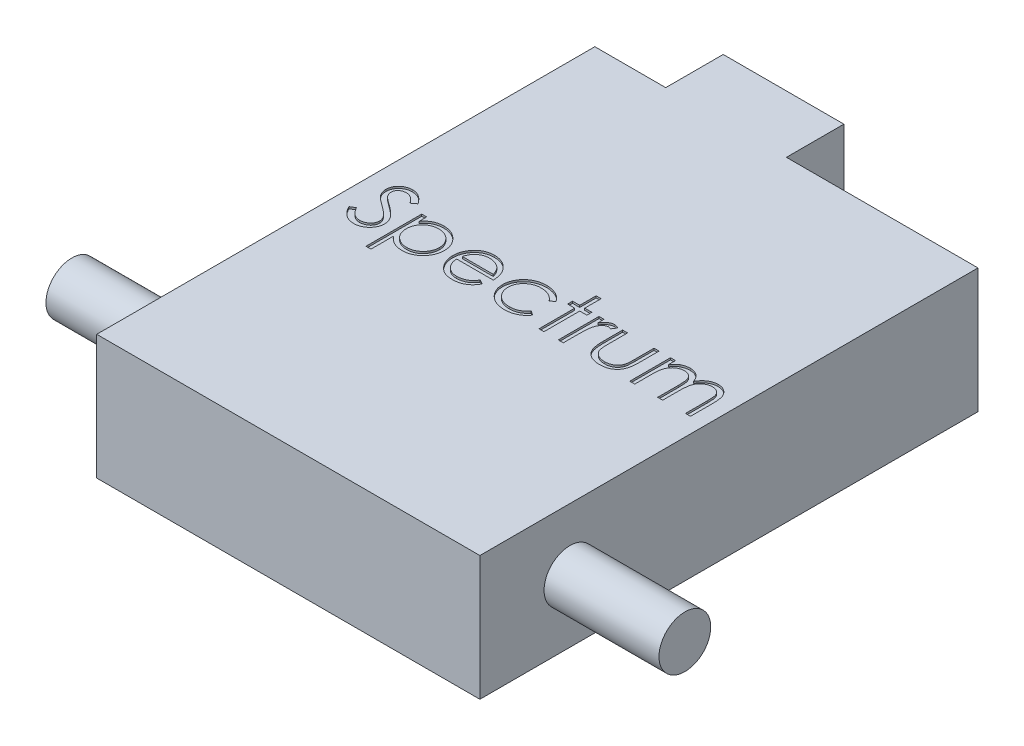
from build123d import *

# Parameters (mm, degrees)
SKETCH1_W           = 20
SKETCH1_H           = 26
BOSS_EXTRUDE1_DEPTH = 6.5
SKETCH2_R           = 1.35
BOSS_EXTRUDE2_DEPTH = 6
SKETCH3_W           = 6.3
SKETCH3_H           = 3.2
BOSS_EXTRUDE3_DEPTH = 3
CUT_EXTRUDE1_DEPTH  = 0.1


with BuildPart() as part:
    # Sketch1 → Boss-Extrude1 (new body)
    with BuildSketch(Plane(origin=(0, 0, 0), x_dir=(1, 0, 0), z_dir=(0, 1, 0))):
        Rectangle(SKETCH1_W, SKETCH1_H)
    extrude(amount=BOSS_EXTRUDE1_DEPTH)

    # Sketch2 → Boss-Extrude2 (add)
    with BuildSketch(Plane(origin=(10, 0, 0), x_dir=(0, 0, -1), z_dir=(1, 0, 0))):
        with Locations((-8.3, 3.25)):
            Circle(SKETCH2_R)
    boss_extrude2 = extrude(amount=BOSS_EXTRUDE2_DEPTH)

    # Mirror1: Boss-Extrude2 across plane
    add(boss_extrude2.mirror(Plane(origin=(0, 0, 0), x_dir=(0, 0, 1), z_dir=(1, 0, 0))))

    # Sketch3 → Boss-Extrude3 (add)
    with BuildSketch(Plane(origin=(0, 0, -13), x_dir=(-1, 0, 0), z_dir=(0, 0, -1))):
        with Locations((3.15, 4.9)):
            Rectangle(SKETCH3_W, SKETCH3_H)
    extrude(amount=BOSS_EXTRUDE3_DEPTH)

    # Sketch4 → Cut-Extrude1 (cut)
    # profile 1 of 8: a face of its own
    with BuildSketch(Plane(origin=(0, 6.5, 0), x_dir=(1, 0, 0), z_dir=(0, 1, 0))):
        with BuildLine():
            Line((-9.191428977, -0.647678782), (-8.945396158, -0.500175694))
            add(Edge.make_bspline(
                [(-8.945396158, -0.500175694), (-8.922513434, -0.538480424), (-8.878671016, -0.611870807), (-8.805535273, -0.711039547), (-8.729753918, -0.795327007), (-8.650765764, -0.864242853), (-8.569052948, -0.918500409), (-8.484082042, -0.956919765), (-8.396139386, -0.980881621), (-8.336289726, -0.983792109), (-8.306410448, -0.985245138)],
                knots=[0, 0, 0, 0, 1.272034388, 2.437168799, 3.508375237, 4.49857839, 5.41946034, 6.295179144, 7.148887113, 8, 8, 8, 8], degree=3))
            add(Edge.make_bspline(
                [(-8.306410448, -0.985245138), (-8.280892862, -0.984534438), (-8.230304188, -0.983125471), (-8.155828918, -0.969587209), (-8.083499408, -0.948788433), (-8.014806392, -0.919001623), (-7.950697717, -0.882963608), (-7.894479531, -0.839435269), (-7.845878804, -0.790701418), (-7.806123249, -0.736332627), (-7.775622053, -0.67786057), (-7.752179006, -0.617842829), (-7.739169382, -0.555336585), (-7.737209629, -0.513251575), (-7.736220644, -0.492013468)],
                knots=[0, 0, 0, 0, 1.095163259, 2.171163733, 3.241058638, 4.321873601, 5.38011039, 6.391990106, 7.366004449, 8.327778327, 9.272591725, 10.192022065, 11.087607919, 12, 12, 12, 12], degree=3))
            add(Edge.make_bspline(
                [(-7.736220644, -0.492013468), (-7.737446604, -0.467781464), (-7.7399388, -0.41852134), (-7.761003132, -0.345844367), (-7.794139679, -0.273921676), (-7.824709567, -0.229432826), (-7.840580537, -0.20633555)],
                knots=[0, 0, 0, 0, 0.938893495, 1.908633276, 2.914225137, 4, 4, 4, 4], degree=3))
            add(Edge.make_bspline(
                [(-7.840580537, -0.20633555), (-7.853611399, -0.189665661), (-7.880968063, -0.154669316), (-7.927998328, -0.102576819), (-7.983184912, -0.048843527), (-8.044639238, 0.008582368), (-8.114599907, 0.067030018), (-8.190875703, 0.129286556), (-8.275414043, 0.192984415), (-8.33470297, 0.235703149), (-8.36529508, 0.257745313)],
                knots=[0, 0, 0, 0, 0.722233717, 1.516239348, 2.393582979, 3.351407094, 4.387010283, 5.505090956, 6.712668013, 8, 8, 8, 8], degree=3))
            add(Edge.make_bspline(
                [(-8.36529508, 0.257745313), (-8.395915986, 0.279555633), (-8.454460827, 0.321255303), (-8.536333827, 0.383142639), (-8.609546991, 0.439724357), (-8.673774911, 0.49153311), (-8.728989338, 0.538575924), (-8.775625365, 0.580401056), (-8.812494986, 0.618139648), (-8.832997276, 0.642621526), (-8.842202298, 0.653613285)],
                knots=[0, 0, 0, 0, 1.452282411, 2.77665338, 3.964542531, 5.026858415, 5.96415736, 6.766646006, 7.446254459, 8, 8, 8, 8], degree=3))
            add(Edge.make_bspline(
                [(-8.842202298, 0.653613285), (-8.855068456, 0.670744028), (-8.880371483, 0.704433934), (-8.913771429, 0.757091568), (-8.942159769, 0.8109952), (-8.964413922, 0.866289678), (-8.983153861, 0.922198723), (-8.995758403, 0.979451813), (-9.003650951, 1.037792045), (-9.004459204, 1.077052319), (-9.004863807, 1.096705566)],
                knots=[0, 0, 0, 0, 1.068054152, 2.10047183, 3.106115577, 4.101338837, 5.06977816, 6.043150881, 7.020423561, 8, 8, 8, 8], degree=3))
            add(Edge.make_bspline(
                [(-9.004863807, 1.096705566), (-9.003778463, 1.127497587), (-9.001630975, 1.188423471), (-8.983469545, 1.277424703), (-8.954803692, 1.362397575), (-8.914644193, 1.442500835), (-8.862874239, 1.515648737), (-8.802964581, 1.58268269), (-8.731608244, 1.639035493), (-8.653315854, 1.688273139), (-8.567619573, 1.726811983), (-8.477819995, 1.755883703), (-8.383774394, 1.772356044), (-8.32007524, 1.774719938), (-8.287753931, 1.775919392)],
                knots=[0, 0, 0, 0, 1.005424448, 1.989358655, 2.955360095, 3.929531133, 4.905563448, 5.876582895, 6.856512386, 7.866279853, 8.892233794, 9.918561126, 10.94386622, 12, 12, 12, 12], degree=3))
            add(Edge.make_bspline(
                [(-8.287753931, 1.775919392), (-8.253457497, 1.774736472), (-8.185252838, 1.772384023), (-8.08492727, 1.751930004), (-7.988334102, 1.718085458), (-7.910631578, 1.679677389), (-7.849818204, 1.64131692), (-7.803440521, 1.606375435), (-7.75644357, 1.566149229), (-7.708448259, 1.520531154), (-7.660267841, 1.469102635), (-7.61118703, 1.412215889), (-7.561091052, 1.350218563), (-7.528863709, 1.305959856), (-7.512342439, 1.283270737)],
                knots=[0, 0, 0, 0, 1.286793592, 2.559021753, 3.825965368, 5.121522368, 5.803751409, 6.523245864, 7.299691795, 8.125521123, 9.008227632, 9.944561021, 10.946284179, 12, 12, 12, 12], degree=3))
            Line((-7.512342439, 1.283270737), (-7.748463984, 1.104284776))
            add(Edge.make_bspline(
                [(-7.748463984, 1.104284776), (-7.762721643, 1.122652574), (-7.790178561, 1.158024658), (-7.831863617, 1.207561044), (-7.871153117, 1.252810938), (-7.909861991, 1.292114143), (-7.945945862, 1.327623), (-7.980968188, 1.358024179), (-8.014424967, 1.383615552), (-8.056598494, 1.410926536), (-8.109582811, 1.437998819), (-8.176093761, 1.460907189), (-8.245599729, 1.474673511), (-8.292939429, 1.476493676), (-8.316904739, 1.477415118)],
                knots=[0, 0, 0, 0, 1.181633172, 2.275549214, 3.290209073, 4.226197932, 5.078386478, 5.862611352, 6.581680152, 7.217281963, 8.414376989, 9.595101626, 10.782541182, 12, 12, 12, 12], degree=3))
            add(Edge.make_bspline(
                [(-8.316904739, 1.477415118), (-8.346970609, 1.476407532), (-8.404949807, 1.474464497), (-8.487264902, 1.453243414), (-8.561350743, 1.419830283), (-8.625007847, 1.373001697), (-8.678008178, 1.317520015), (-8.716347063, 1.253674741), (-8.739422646, 1.183174136), (-8.742238499, 1.133995032), (-8.743672567, 1.108948905)],
                knots=[0, 0, 0, 0, 1.14458467, 2.207223713, 3.21896685, 4.227309161, 5.202851033, 6.127160689, 7.046193047, 8, 8, 8, 8], degree=3))
            add(Edge.make_bspline(
                [(-8.743672567, 1.108948905), (-8.743345664, 1.093356158), (-8.742691322, 1.062145166), (-8.733565255, 1.016034668), (-8.721840992, 0.970040656), (-8.70326203, 0.924369913), (-8.677612691, 0.878223711), (-8.643930708, 0.83080742), (-8.60151071, 0.781703113), (-8.569016313, 0.749765553), (-8.551860251, 0.732903483)],
                knots=[0, 0, 0, 0, 0.858281714, 1.717966888, 2.583508476, 3.4729293, 4.427298488, 5.488583878, 6.674047936, 8, 8, 8, 8], degree=3))
            add(Edge.make_bspline(
                [(-8.551860251, 0.732903483), (-8.545489455, 0.72721817), (-8.530353902, 0.713711169), (-8.502683385, 0.691598421), (-8.466142856, 0.664321354), (-8.42168649, 0.630571068), (-8.368494582, 0.59142059), (-8.306561285, 0.547370509), (-8.236576963, 0.496990815), (-8.186915346, 0.461768503), (-8.160656408, 0.443144452)],
                knots=[0, 0, 0, 0, 0.420754252, 0.999615792, 1.744751191, 2.668019286, 3.750313428, 4.999500688, 6.413464383, 8, 8, 8, 8], degree=3))
            add(Edge.make_bspline(
                [(-8.160656408, 0.443144452), (-8.129069312, 0.420159345), (-8.067905279, 0.375651871), (-7.980877518, 0.308782404), (-7.901968798, 0.243383039), (-7.830902074, 0.179871422), (-7.766975264, 0.118729311), (-7.710897588, 0.059221119), (-7.66209765, 0.001773176), (-7.609561122, -0.071879139), (-7.55587822, -0.16233579), (-7.509775967, -0.273162992), (-7.480706436, -0.384421004), (-7.476905004, -0.459199451), (-7.475029405, -0.496094581)],
                knots=[0, 0, 0, 0, 1.163667725, 2.253281268, 3.268753668, 4.215851969, 5.092017293, 5.902905408, 6.650798638, 7.335211899, 8.59617414, 9.77448103, 10.901945474, 12, 12, 12, 12], degree=3))
            add(Edge.make_bspline(
                [(-7.475029405, -0.496094581), (-7.475575846, -0.522187186), (-7.476658118, -0.573865694), (-7.48909883, -0.649748636), (-7.507326076, -0.723449425), (-7.534798109, -0.794057058), (-7.568328735, -0.862863269), (-7.610875907, -0.928063172), (-7.660193071, -0.991099802), (-7.716766386, -1.050292265), (-7.778671699, -1.104630738), (-7.844100938, -1.152967821), (-7.913161195, -1.19327154), (-7.985477828, -1.226159949), (-8.06106745, -1.251882641), (-8.139904637, -1.270520009), (-8.222119343, -1.281958538), (-8.277999744, -1.28314579), (-8.306410448, -1.283749412)],
                knots=[0, 0, 0, 0, 0.983748083, 1.948392443, 2.894712957, 3.844097841, 4.80183111, 5.778335162, 6.776009319, 7.81870978, 8.863265674, 9.881300176, 10.883814829, 11.87499822, 12.874611388, 13.892143829, 14.928324115, 16, 16, 16, 16], degree=3))
            add(Edge.make_bspline(
                [(-8.306410448, -1.283749412), (-8.328392694, -1.28332434), (-8.372080344, -1.28247955), (-8.436699478, -1.275011187), (-8.500013172, -1.264444626), (-8.561226953, -1.247668926), (-8.621129491, -1.227315154), (-8.679460257, -1.202253695), (-8.736247521, -1.172220522), (-8.791809523, -1.137881743), (-8.846004952, -1.09791944), (-8.898325486, -1.051374812), (-8.950487791, -0.999531556), (-9.000952251, -0.940981819), (-9.050739621, -0.876671521), (-9.098868275, -0.805998968), (-9.146334441, -0.729349109), (-9.176116708, -0.675410701), (-9.191428977, -0.647678782)],
                knots=[0, 0, 0, 0, 0.915332311, 1.819136955, 2.706846663, 3.586547465, 4.459518054, 5.340707479, 6.227863349, 7.133153174, 8.059268498, 9.028702269, 10.047606654, 11.120612155, 12.245963614, 13.433783089, 14.680604001, 16, 16, 16, 16], degree=3))
        make_face()
    # profile 2 of 8: a face of its own
    with BuildSketch(Plane(origin=(0, 6.5, 0), x_dir=(1, 0, 0), z_dir=(0, 1, 0))):
        with BuildLine():
            Line((-6.952646926, 0.917719605), (-6.691455687, 0.917719605))
            Line((-6.691455687, 0.917719605), (-6.691455687, 0.524183698))
            add(Edge.make_bspline(
                [(-6.691455687, 0.524183698), (-6.66371735, 0.559888468), (-6.609813445, 0.629273544), (-6.516908866, 0.719072478), (-6.418847109, 0.79480593), (-6.313104676, 0.854163905), (-6.201324977, 0.898918473), (-6.083966734, 0.93199698), (-5.960033904, 0.951489683), (-5.875302151, 0.953836028), (-5.832089868, 0.955032639)],
                knots=[0, 0, 0, 0, 1.0828784, 2.104357462, 3.088488658, 4.04616522, 5.001424249, 5.969181776, 6.964304535, 8, 8, 8, 8], degree=3))
            add(Edge.make_bspline(
                [(-5.832089868, 0.955032639), (-5.794344589, 0.953940669), (-5.719739061, 0.951782331), (-5.609922197, 0.937169499), (-5.50416981, 0.912125204), (-5.403080184, 0.876035276), (-5.305570361, 0.831418198), (-5.213083889, 0.775108258), (-5.124180176, 0.709909777), (-5.041095107, 0.634877447), (-4.964325494, 0.553694894), (-4.897929592, 0.466363847), (-4.840659324, 0.375756268), (-4.794366822, 0.280467486), (-4.758104404, 0.181247865), (-4.732314223, 0.077696536), (-4.716965813, -0.029802564), (-4.714906526, -0.102897862), (-4.713864875, -0.139871708)],
                knots=[0, 0, 0, 0, 1.041296284, 2.058176809, 3.050446431, 4.034000596, 5.01514041, 6.003636468, 7.015969324, 8.052561599, 9.08815499, 10.094063707, 11.074456064, 12.040834395, 13.011057502, 13.983766392, 14.980127149, 16, 16, 16, 16], degree=3))
            add(Edge.make_bspline(
                [(-4.713864875, -0.139871708), (-4.714883925, -0.177625889), (-4.716893637, -0.252082584), (-4.732481002, -0.361420366), (-4.75739157, -0.466600641), (-4.793196499, -0.56744846), (-4.839465047, -0.66389439), (-4.895764613, -0.755868875), (-4.962194014, -0.843342448), (-5.038115249, -0.925127568), (-5.120482483, -1.000465211), (-5.208524657, -1.066355439), (-5.300875442, -1.121687761), (-5.397062357, -1.167907639), (-5.497908826, -1.202742985), (-5.602944331, -1.227870525), (-5.712111687, -1.243365996), (-5.786369848, -1.245405069), (-5.823927642, -1.246436378)],
                knots=[0, 0, 0, 0, 1.038740735, 2.04854663, 3.033179607, 4.009277356, 4.987731542, 5.972001279, 6.972200261, 8.005528982, 9.039189865, 10.040446548, 11.026516639, 11.997840187, 12.972163198, 13.956796175, 14.96660207, 16, 16, 16, 16], degree=3))
            add(Edge.make_bspline(
                [(-5.823927642, -1.246436378), (-5.866193188, -1.245359683), (-5.949680034, -1.243232897), (-6.071749287, -1.221679673), (-6.189227717, -1.189468066), (-6.300813778, -1.142320153), (-6.407391417, -1.082236251), (-6.508357768, -1.008968419), (-6.604249139, -0.922669888), (-6.661965826, -0.857200633), (-6.691455687, -0.823749662)],
                knots=[0, 0, 0, 0, 1.014726462, 2.004382257, 2.969841629, 3.936926163, 4.907207904, 5.903978561, 6.929055279, 8, 8, 8, 8], degree=3))
            Line((-6.691455687, -0.823749662), (-6.691455687, -1.992697061))
            Line((-6.691455687, -1.992697061), (-6.952646926, -1.992697061))
            Line((-6.952646926, -1.992697061), (-6.952646926, 0.917719605))
        make_face()
        with BuildLine():
            add(Edge.make_bspline(
                [(-5.834421933, 0.6938414), (-5.864008033, 0.693308995), (-5.922255439, 0.692260826), (-6.007632278, 0.679809275), (-6.089868536, 0.661733308), (-6.168135421, 0.634365496), (-6.243183106, 0.600771959), (-6.314433569, 0.558793762), (-6.381836796, 0.509190279), (-6.445223202, 0.452911682), (-6.50248631, 0.390899277), (-6.553179887, 0.324718224), (-6.5957612, 0.254452334), (-6.631103654, 0.180756125), (-6.657998633, 0.103051921), (-6.677087407, 0.021782267), (-6.689086933, -0.063141789), (-6.690657674, -0.120980921), (-6.691455687, -0.150365998)],
                knots=[0, 0, 0, 0, 1.05670511, 2.080379991, 3.077984906, 4.06214886, 5.038337365, 6.01289324, 7.01187578, 8.025460281, 9.038092164, 10.024533457, 11.000252242, 11.969694649, 12.940728589, 13.933144304, 14.949937299, 16, 16, 16, 16], degree=3))
            add(Edge.make_bspline(
                [(-6.691455687, -0.150365998), (-6.690132814, -0.188939923), (-6.687541195, -0.264509508), (-6.666471967, -0.374925828), (-6.632182881, -0.479411163), (-6.583513469, -0.577085609), (-6.522022539, -0.666878479), (-6.44793318, -0.747281322), (-6.361915773, -0.817788736), (-6.265400376, -0.87717891), (-6.161937449, -0.925398748), (-6.054014283, -0.959919791), (-5.943115034, -0.981184317), (-5.868135782, -0.983884201), (-5.83034082, -0.985245138)],
                knots=[0, 0, 0, 0, 1.03728447, 2.032128127, 3.01272805, 3.987917167, 4.958271349, 5.931593992, 6.91984656, 7.941419022, 8.973179163, 9.983609215, 10.983593296, 12, 12, 12, 12], degree=3))
            add(Edge.make_bspline(
                [(-5.83034082, -0.985245138), (-5.793307208, -0.983950937), (-5.719802146, -0.98138218), (-5.61156947, -0.959148103), (-5.506386481, -0.92518352), (-5.406450945, -0.875656913), (-5.312632842, -0.814962204), (-5.227913479, -0.742151867), (-5.153899992, -0.657758146), (-5.090815168, -0.563786195), (-5.039981427, -0.463023093), (-5.001788245, -0.358762498), (-4.979745104, -0.251371929), (-4.976621156, -0.179029188), (-4.975056114, -0.142786788)],
                knots=[0, 0, 0, 0, 1.00104056, 1.986885549, 2.97790532, 3.984399681, 4.995088187, 5.994304198, 6.996462723, 8.023150851, 9.048424203, 10.043036403, 11.019596776, 12, 12, 12, 12], degree=3))
            add(Edge.make_bspline(
                [(-4.975056114, -0.142786788), (-4.976265795, -0.106319277), (-4.978675731, -0.033668372), (-5.002413952, 0.073404114), (-5.038087327, 0.17808596), (-5.090108157, 0.277472989), (-5.151810046, 0.371250009), (-5.226438948, 0.4540338), (-5.310106106, 0.526520365), (-5.403812512, 0.586404608), (-5.504380235, 0.634040225), (-5.61024865, 0.668868465), (-5.720880741, 0.689801637), (-5.796241952, 0.692482967), (-5.834421933, 0.6938414)],
                knots=[0, 0, 0, 0, 0.983928682, 1.960191568, 2.949917689, 3.96440592, 4.982380491, 5.975291189, 6.965713506, 7.964880129, 8.970154049, 9.96478489, 10.968906225, 12, 12, 12, 12], degree=3))
        make_face(mode=Mode.SUBTRACT)
    # profile 3 of 8: a face of its own
    with BuildSketch(Plane(origin=(0, 6.5, 0), x_dir=(1, 0, 0), z_dir=(0, 1, 0))):
        with BuildLine():
            Line((-2.445932016, -0.537488728), (-2.213891584, -0.659339105))
            add(Edge.make_bspline(
                [(-2.213891584, -0.659339105), (-2.232382372, -0.692138114), (-2.268358123, -0.755951995), (-2.330225888, -0.843623608), (-2.39508001, -0.922494), (-2.465848012, -0.990456099), (-2.54041262, -1.049705019), (-2.619187333, -1.101541888), (-2.702582261, -1.145712468), (-2.790601348, -1.182926326), (-2.883983772, -1.211539458), (-2.982955831, -1.231749576), (-3.087707128, -1.244242139), (-3.159508088, -1.245693306), (-3.196273813, -1.246436378)],
                knots=[0, 0, 0, 0, 1.120438281, 2.179929193, 3.190490725, 4.156257408, 5.095198341, 6.022838206, 6.959905092, 7.901321166, 8.864066838, 9.862729781, 10.905609505, 12, 12, 12, 12], degree=3))
            add(Edge.make_bspline(
                [(-3.196273813, -1.246436378), (-3.237137707, -1.245482447), (-3.316851327, -1.243621604), (-3.432885271, -1.227579001), (-3.542133514, -1.201408236), (-3.644589912, -1.164848795), (-3.740003559, -1.11709524), (-3.828564091, -1.0589206), (-3.910737233, -0.990623719), (-3.983933554, -0.911613021), (-4.049828616, -0.827059632), (-4.107975266, -0.738952269), (-4.156585403, -0.647512611), (-4.196127663, -0.553322776), (-4.228063137, -0.456976432), (-4.250320926, -0.357596955), (-4.263151496, -0.255453318), (-4.265117645, -0.186353926), (-4.266108465, -0.151532031)],
                knots=[0, 0, 0, 0, 1.145258523, 2.234067595, 3.276747158, 4.290159414, 5.277019952, 6.260822364, 7.254936242, 8.264827045, 9.274100331, 10.257902744, 11.220704747, 12.172965371, 13.118907548, 14.062713208, 15.023725156, 16, 16, 16, 16], degree=3))
            add(Edge.make_bspline(
                [(-4.266108465, -0.151532031), (-4.265227738, -0.118856508), (-4.263482255, -0.054097937), (-4.252480225, 0.041750852), (-4.232981853, 0.134907845), (-4.206225707, 0.225450448), (-4.171673867, 0.313227063), (-4.129404456, 0.398291111), (-4.079351628, 0.480552076), (-4.040707387, 0.532443253), (-4.021241678, 0.558581651)],
                knots=[0, 0, 0, 0, 1.024358464, 2.0301432, 3.019427413, 4.004406732, 4.986367066, 5.972626655, 6.978780325, 8, 8, 8, 8], degree=3))
            add(Edge.make_bspline(
                [(-4.021241678, 0.558581651), (-3.99487523, 0.59007142), (-3.942977556, 0.652053441), (-3.85520242, 0.733493823), (-3.760156364, 0.801717129), (-3.659030505, 0.858268301), (-3.550649521, 0.901237399), (-3.436470307, 0.933258288), (-3.315192757, 0.951201431), (-3.232283118, 0.95373585), (-3.189860635, 0.955032639)],
                knots=[0, 0, 0, 0, 1.030682036, 2.02871468, 2.997146059, 3.962720338, 4.930598197, 5.918074684, 6.934738563, 8, 8, 8, 8], degree=3))
            add(Edge.make_bspline(
                [(-3.189860635, 0.955032639), (-3.146247953, 0.953906683), (-3.060689814, 0.951697814), (-2.935930961, 0.931219845), (-2.817883866, 0.898745786), (-2.706595765, 0.852882783), (-2.602055378, 0.793710227), (-2.504942216, 0.720416089), (-2.413595452, 0.635250572), (-2.360452426, 0.569755213), (-2.333409897, 0.536427037)],
                knots=[0, 0, 0, 0, 1.056321875, 2.072262726, 3.055038591, 4.01806755, 4.982017516, 5.957941055, 6.960871419, 8, 8, 8, 8], degree=3))
            add(Edge.make_bspline(
                [(-2.333409897, 0.536427037), (-2.315010294, 0.511311321), (-2.278333562, 0.461247066), (-2.232392967, 0.379613074), (-2.19251411, 0.294204324), (-2.160638427, 0.203640226), (-2.134827604, 0.108993825), (-2.11615369, 0.009588507), (-2.105202525, -0.094546128), (-2.103049899, -0.165499222), (-2.101952482, -0.20167142)],
                knots=[0, 0, 0, 0, 0.94817472, 1.890038105, 2.849395472, 3.817997239, 4.812318967, 5.836947057, 6.897266129, 8, 8, 8, 8], degree=3))
            Line((-2.101952482, -0.20167142), (-4.004917225, -0.20167142))
            add(Edge.make_bspline(
                [(-4.004917225, -0.20167142), (-4.003636969, -0.229694961), (-4.001119397, -0.284802124), (-3.989381984, -0.365437948), (-3.970881069, -0.442250781), (-3.944879354, -0.514664477), (-3.913391269, -0.583624827), (-3.874819337, -0.648620283), (-3.828801863, -0.709354799), (-3.777474004, -0.766371639), (-3.720340783, -0.81714657), (-3.660234236, -0.862592124), (-3.596293575, -0.900681659), (-3.529022967, -0.931598508), (-3.458531191, -0.955801796), (-3.384796038, -0.972322835), (-3.307962604, -0.983388328), (-3.255586967, -0.98461874), (-3.228922717, -0.985245138)],
                knots=[0, 0, 0, 0, 1.094153842, 2.151609401, 3.174256925, 4.172055639, 5.149267565, 6.128595816, 7.11444997, 8.118368179, 9.117203808, 10.09244225, 11.054858984, 12.015122123, 12.976791628, 13.957293641, 14.960065497, 16, 16, 16, 16], degree=3))
            add(Edge.make_bspline(
                [(-3.228922717, -0.985245138), (-3.202852745, -0.98473951), (-3.15112492, -0.983736247), (-3.074089635, -0.973980605), (-2.998302778, -0.958205917), (-2.92407802, -0.936677158), (-2.852921787, -0.910419501), (-2.787025338, -0.878735161), (-2.726421969, -0.843685639), (-2.669779467, -0.803596999), (-2.61483829, -0.754528881), (-2.560336592, -0.693297273), (-2.501898208, -0.620879846), (-2.465318767, -0.566375504), (-2.445932016, -0.537488728)],
                knots=[0, 0, 0, 0, 0.99110716, 1.966546729, 2.947904876, 3.932708344, 4.903319531, 5.828989031, 6.710028674, 7.56322171, 8.463672341, 9.504779593, 10.677557249, 12, 12, 12, 12], degree=3))
        make_face()
        with BuildLine():
            add(Edge.make_bspline(
                [(-2.363143721, 0.059519819), (-2.372703712, 0.094164482), (-2.391103617, 0.160844307), (-2.429551355, 0.253180095), (-2.472851321, 0.335243784), (-2.524092725, 0.406407325), (-2.58215032, 0.469607865), (-2.64921063, 0.524838081), (-2.724412382, 0.574246521), (-2.807366858, 0.615950713), (-2.895213033, 0.651449363), (-2.987187348, 0.67525251), (-3.081033973, 0.691558778), (-3.144509567, 0.693077274), (-3.176451263, 0.6938414)],
                knots=[0, 0, 0, 0, 1.154881502, 2.222775134, 3.210006277, 4.132804581, 5.035138423, 5.962687519, 6.919655026, 7.923214229, 8.944639381, 9.960483929, 10.97369054, 12, 12, 12, 12], degree=3))
            add(Edge.make_bspline(
                [(-3.176451263, 0.6938414), (-3.202519814, 0.693332766), (-3.254051859, 0.692327304), (-3.329973045, 0.682789345), (-3.402882889, 0.667023331), (-3.47331937, 0.645432233), (-3.540359461, 0.616653532), (-3.605382134, 0.582906647), (-3.666734047, 0.541710461), (-3.705102731, 0.510312175), (-3.724486453, 0.494449874)],
                knots=[0, 0, 0, 0, 1.04873581, 2.073130211, 3.073294108, 4.04793562, 5.032784715, 6.005352987, 6.992311501, 8, 8, 8, 8], degree=3))
            add(Edge.make_bspline(
                [(-3.724486453, 0.494449874), (-3.738367712, 0.481898231), (-3.766459996, 0.456496767), (-3.80399649, 0.412733075), (-3.839936371, 0.365541449), (-3.872644176, 0.313116426), (-3.902644407, 0.25605498), (-3.930717436, 0.194838411), (-3.955985184, 0.129002183), (-3.970201414, 0.083123672), (-3.977515466, 0.059519819)],
                knots=[0, 0, 0, 0, 0.879870761, 1.780643979, 2.707998968, 3.669668524, 4.684282772, 5.740141944, 6.837334558, 8, 8, 8, 8], degree=3))
            Line((-3.977515466, 0.059519819), (-2.363143721, 0.059519819))
        make_face(mode=Mode.SUBTRACT)
    # profile 4 of 8: a face of its own
    with BuildSketch(Plane(origin=(0, 6.5, 0), x_dir=(1, 0, 0), z_dir=(0, 1, 0))):
        with BuildLine():
            Line((0.509959911, 0.456553823), (0.291328852, 0.320711058))
            add(Edge.make_bspline(
                [(0.291328852, 0.320711058), (0.267355446, 0.350504074), (0.220167866, 0.409146567), (0.138227799, 0.48482566), (0.050905808, 0.549825277), (-0.043290283, 0.60279798), (-0.144228356, 0.64372796), (-0.251510349, 0.672690934), (-0.365120962, 0.690739046), (-0.443008035, 0.692790338), (-0.482916608, 0.6938414)],
                knots=[0, 0, 0, 0, 1.026593902, 2.0206758, 2.988051866, 3.946915611, 4.916868779, 5.907761954, 6.927957743, 8, 8, 8, 8], degree=3))
            add(Edge.make_bspline(
                [(-0.482916608, 0.6938414), (-0.514813907, 0.692962585), (-0.577634771, 0.691231784), (-0.669858518, 0.680412939), (-0.757705166, 0.660753483), (-0.841725327, 0.63484998), (-0.921321413, 0.600132625), (-0.996701968, 0.557881894), (-1.068535617, 0.508778973), (-1.134740728, 0.451892347), (-1.195301516, 0.390026312), (-1.247771268, 0.323707317), (-1.293453944, 0.254921788), (-1.329298599, 0.181952036), (-1.358631583, 0.106467425), (-1.377929076, 0.027043106), (-1.390788706, -0.055303398), (-1.392259987, -0.111448113), (-1.393004832, -0.139871708)],
                knots=[0, 0, 0, 0, 1.112346261, 2.190735716, 3.231507886, 4.247384806, 5.251966152, 6.253067467, 7.256802811, 8.280671706, 9.291813951, 10.270744147, 11.225547591, 12.165006084, 13.100104208, 14.043489273, 15.009504848, 16, 16, 16, 16], degree=3))
            add(Edge.make_bspline(
                [(-1.393004832, -0.139871708), (-1.391525299, -0.177099438), (-1.388586169, -0.251053289), (-1.365551086, -0.360217282), (-1.327845052, -0.465760374), (-1.276240994, -0.566933224), (-1.21098352, -0.660560626), (-1.134337644, -0.744533177), (-1.046260883, -0.817223767), (-0.947529296, -0.877488123), (-0.840461101, -0.925935224), (-0.726214686, -0.960450548), (-0.605723619, -0.981282789), (-0.523228485, -0.983907106), (-0.481167559, -0.985245138)],
                knots=[0, 0, 0, 0, 0.966302908, 1.919585723, 2.883856336, 3.870342332, 4.860282998, 5.839159637, 6.814385684, 7.815993281, 8.834850808, 9.858348828, 10.908058873, 12, 12, 12, 12], degree=3))
            add(Edge.make_bspline(
                [(-0.481167559, -0.985245138), (-0.442621016, -0.984164545), (-0.36686683, -0.982040891), (-0.256131891, -0.964138533), (-0.150708358, -0.934831773), (-0.050599978, -0.893963162), (0.044010322, -0.841137007), (0.132511249, -0.775977625), (0.216663817, -0.700359512), (0.266138386, -0.64188677), (0.291328852, -0.612114797)],
                knots=[0, 0, 0, 0, 1.039848629, 2.043578496, 3.018386758, 3.987534228, 4.954977003, 5.934852016, 6.948509513, 8, 8, 8, 8], degree=3))
            Line((0.291328852, -0.612114797), (0.509959911, -0.755536772))
            add(Edge.make_bspline(
                [(0.509959911, -0.755536772), (0.496997995, -0.774571501), (0.471117184, -0.812577781), (0.427853736, -0.866166133), (0.381187423, -0.916326484), (0.331300306, -0.962991598), (0.27884378, -1.007278177), (0.222025869, -1.04706904), (0.162678639, -1.084600794), (0.100105381, -1.118372332), (0.034953044, -1.148729076), (-0.032686694, -1.17483233), (-0.102519907, -1.197259257), (-0.174628703, -1.215085432), (-0.249155242, -1.229313909), (-0.325906783, -1.238755052), (-0.404856893, -1.245802652), (-0.458219092, -1.246223304), (-0.485248672, -1.246436378)],
                knots=[0, 0, 0, 0, 0.954134338, 1.905101784, 2.851144739, 3.791306361, 4.734911809, 5.6936923, 6.663572882, 7.643865596, 8.638447847, 9.640600242, 10.646758161, 11.676244097, 12.717260333, 13.78922464, 14.880174919, 16, 16, 16, 16], degree=3))
            add(Edge.make_bspline(
                [(-0.485248672, -1.246436378), (-0.526502485, -1.245695236), (-0.607360256, -1.244242593), (-0.725708198, -1.228269831), (-0.838810039, -1.204190194), (-0.946627138, -1.16962797), (-1.04917628, -1.125136202), (-1.146361843, -1.070788815), (-1.237862032, -1.006134499), (-1.32277201, -0.93232403), (-1.400755749, -0.852295354), (-1.467717111, -0.765939202), (-1.525796779, -0.676430545), (-1.572436242, -0.581792505), (-1.609562287, -0.483282906), (-1.634928508, -0.380112593), (-1.651334725, -0.273132118), (-1.653233463, -0.200178049), (-1.654196072, -0.163192354)],
                knots=[0, 0, 0, 0, 1.1129367, 2.181364009, 3.217532258, 4.231199276, 5.232079859, 6.230262199, 7.231623845, 8.250719726, 9.263571943, 10.242672461, 11.195837495, 12.138959767, 13.085126421, 14.0317438, 15.002148558, 16, 16, 16, 16], degree=3))
            add(Edge.make_bspline(
                [(-1.654196072, -0.163192354), (-1.653829346, -0.138097549), (-1.653099867, -0.088179839), (-1.644732895, -0.014093048), (-1.633924046, 0.059007093), (-1.615608597, 0.130193989), (-1.5944535, 0.200547316), (-1.567448549, 0.269219097), (-1.535770414, 0.336528447), (-1.49980436, 0.402301976), (-1.45931735, 0.465457635), (-1.414512539, 0.525124224), (-1.367077457, 0.582018517), (-1.314792976, 0.634176311), (-1.259877859, 0.683683489), (-1.200778459, 0.729217477), (-1.137833754, 0.770912098), (-1.071989051, 0.80953833), (-1.003282669, 0.84393067), (-0.932129908, 0.873561404), (-0.858959514, 0.898884171), (-0.783654441, 0.918931885), (-0.706714522, 0.935743635), (-0.627533446, 0.94631913), (-0.546414127, 0.953791644), (-0.491485399, 0.954615535), (-0.463677074, 0.955032639)],
                knots=[0, 0, 0, 0, 0.990994727, 1.971252077, 2.943264845, 3.907940874, 4.872158414, 5.844625996, 6.82015047, 7.809835459, 8.804511986, 9.781214284, 10.756496977, 11.728388426, 12.696359165, 13.676225489, 14.672885716, 15.677705647, 16.690706858, 17.706033469, 18.721040654, 19.747369689, 20.783475414, 21.830280724, 22.901553713, 24, 24, 24, 24], degree=3))
            add(Edge.make_bspline(
                [(-0.463677074, 0.955032639), (-0.42885177, 0.954266043), (-0.359375235, 0.952736682), (-0.256312636, 0.939865446), (-0.154768037, 0.920460104), (-0.056523094, 0.89171115), (0.037231001, 0.856899527), (0.124988754, 0.817806216), (0.204684364, 0.772408204), (0.277800341, 0.722748085), (0.344473428, 0.666734284), (0.405388027, 0.603697189), (0.461793273, 0.53396487), (0.49377186, 0.482570462), (0.509959911, 0.456553823)],
                knots=[0, 0, 0, 0, 1.095225653, 2.184976855, 3.262915854, 4.344593502, 5.400796181, 6.407717688, 7.363229445, 8.282371371, 9.184954523, 10.097238608, 11.036792983, 12, 12, 12, 12], degree=3))
        make_face()
    # profile 5 of 8: a face of its own
    with BuildSketch(Plane(origin=(0, 6.5, 0), x_dir=(1, 0, 0), z_dir=(0, 1, 0))):
        Polygon((1.293533629, 1.775919392), (1.554724869, 1.775919392), (1.554724869, 0.917719605), (1.927855211, 0.917719605), (1.927855211, 0.656528366), (1.554724869, 0.656528366), (1.554724869, -1.209123344), (1.293533629, -1.209123344), (1.293533629, 0.656528366), (0.920403287, 0.656528366), (0.920403287, 0.917719605), (1.293533629, 0.917719605), align=None)
    # profile 6 of 8: a face of its own
    with BuildSketch(Plane(origin=(0, 6.5, 0), x_dir=(1, 0, 0), z_dir=(0, 1, 0))):
        with BuildLine():
            Line((2.300985552, 0.917719605), (2.562176792, 0.917719605))
            Line((2.562176792, 0.917719605), (2.562176792, 0.604639928))
            add(Edge.make_bspline(
                [(2.562176792, 0.604639928), (2.581459349, 0.633790518), (2.61833709, 0.689540796), (2.6796329, 0.763273542), (2.742417516, 0.82432165), (2.806991502, 0.872970111), (2.87382972, 0.909402806), (2.941465268, 0.936089693), (3.010962251, 0.951870234), (3.057663565, 0.953977092), (3.081061173, 0.955032639)],
                knots=[0, 0, 0, 0, 1.2804753, 2.448899062, 3.506932113, 4.484331642, 5.4025378, 6.288909075, 7.142734305, 8, 8, 8, 8], degree=3))
            add(Edge.make_bspline(
                [(3.081061173, 0.955032639), (3.099210803, 0.95404266), (3.136554846, 0.952005713), (3.193085607, 0.937694092), (3.251330072, 0.914844808), (3.288868117, 0.893357432), (3.308437475, 0.882155619)],
                knots=[0, 0, 0, 0, 0.901110191, 1.854092781, 2.881294221, 4, 4, 4, 4], degree=3))
            Line((3.308437475, 0.882155619), (3.1650155, 0.65594535))
            add(Edge.make_bspline(
                [(3.1650155, 0.65594535), (3.15245163, 0.661550202), (3.128602998, 0.672189284), (3.093715779, 0.684780587), (3.061550405, 0.692194596), (3.041058113, 0.693317781), (3.0315048, 0.6938414)],
                knots=[0, 0, 0, 0, 1.180555205, 2.24091978, 3.179933427, 4, 4, 4, 4], degree=3))
            add(Edge.make_bspline(
                [(3.0315048, 0.6938414), (3.010545032, 0.692444369), (2.967793182, 0.689594831), (2.905024226, 0.667193929), (2.844115687, 0.631000619), (2.795743179, 0.590860891), (2.758288401, 0.552154181), (2.731562273, 0.518353099), (2.707045965, 0.480452296), (2.683621085, 0.439099696), (2.66227834, 0.393589223), (2.642358891, 0.344375563), (2.624348516, 0.291401714), (2.614078699, 0.254495535), (2.608818084, 0.235590699)],
                knots=[0, 0, 0, 0, 1.125678352, 2.296057538, 3.5422874, 4.923748041, 5.663163013, 6.437101912, 7.23742474, 8.08941207, 8.991984279, 9.93940061, 10.944477711, 12, 12, 12, 12], degree=3))
            add(Edge.make_bspline(
                [(2.608818084, 0.235590699), (2.604882874, 0.218729264), (2.596166682, 0.181382465), (2.587691933, 0.118726579), (2.579318649, 0.044699168), (2.573417473, -0.040905827), (2.567947518, -0.137874627), (2.564862408, -0.246354958), (2.562281999, -0.366458167), (2.562212925, -0.45042315), (2.562176792, -0.494345532)],
                knots=[0, 0, 0, 0, 0.566838948, 1.255505196, 2.06880316, 3.007127437, 4.065329342, 5.249902469, 6.561414163, 8, 8, 8, 8], degree=3))
            Line((2.562176792, -0.494345532), (2.562176792, -1.209123344))
            Line((2.562176792, -1.209123344), (2.300985552, -1.209123344))
            Line((2.300985552, -1.209123344), (2.300985552, 0.917719605))
        make_face()
    # profile 7 of 8: a face of its own
    with BuildSketch(Plane(origin=(0, 6.5, 0), x_dir=(1, 0, 0), z_dir=(0, 1, 0))):
        with BuildLine():
            Line((3.532315681, 0.917719605), (3.79350692, 0.917719605))
            Line((3.79350692, 0.917719605), (3.79350692, -0.068743736))
            add(Edge.make_bspline(
                [(3.79350692, -0.068743736), (3.793624921, -0.09770051), (3.79385065, -0.153093463), (3.79538148, -0.232801615), (3.79898216, -0.305492775), (3.803484012, -0.371208932), (3.80927336, -0.429938972), (3.816161369, -0.481477759), (3.823860187, -0.526409756), (3.831396265, -0.553471106), (3.834901067, -0.56605652)],
                knots=[0, 0, 0, 0, 1.388932606, 2.656963016, 3.823490214, 4.879454478, 5.816252168, 6.653371382, 7.373723809, 8, 8, 8, 8], degree=3))
            add(Edge.make_bspline(
                [(3.834901067, -0.56605652), (3.840523539, -0.581874943), (3.851651593, -0.613182928), (3.87183615, -0.658409976), (3.896806142, -0.700299422), (3.924130654, -0.740466559), (3.955645816, -0.777721544), (3.990952888, -0.812001466), (4.028869994, -0.844601534), (4.085211522, -0.883172698), (4.162262114, -0.924513362), (4.263422173, -0.960183278), (4.373106818, -0.981500683), (4.448914623, -0.983973918), (4.487879166, -0.985245138)],
                knots=[0, 0, 0, 0, 0.725840625, 1.436591201, 2.137033971, 2.831655856, 3.53531722, 4.242432219, 4.957935707, 5.694543706, 7.190802206, 8.724350549, 10.316345118, 12, 12, 12, 12], degree=3))
            add(Edge.make_bspline(
                [(4.487879166, -0.985245138), (4.526840088, -0.983946886), (4.602222265, -0.981435007), (4.710701784, -0.960826315), (4.809865014, -0.926395513), (4.898716668, -0.878325897), (4.976853739, -0.819500503), (5.041967592, -0.750474726), (5.0956916, -0.673432349), (5.119149077, -0.615952219), (5.130945989, -0.587045102)],
                knots=[0, 0, 0, 0, 1.157059328, 2.238695713, 3.266970494, 4.264342957, 5.228770407, 6.160125903, 7.074715775, 8, 8, 8, 8], degree=3))
            add(Edge.make_bspline(
                [(5.130945989, -0.587045102), (5.134433691, -0.575431459), (5.142144149, -0.549756532), (5.150428318, -0.506200277), (5.15789101, -0.454257984), (5.164263306, -0.393589759), (5.168807849, -0.324354146), (5.171257611, -0.246572782), (5.17402523, -0.160489841), (5.174067237, -0.100229448), (5.174089185, -0.068743736)],
                knots=[0, 0, 0, 0, 0.557542046, 1.232589297, 2.036731608, 2.971723315, 4.038036528, 5.22795436, 6.551621927, 8, 8, 8, 8], degree=3))
            Line((5.174089185, -0.068743736), (5.174089185, 0.917719605))
            Line((5.174089185, 0.917719605), (5.435280424, 0.917719605))
            Line((5.435280424, 0.917719605), (5.435280424, -0.117717094))
            add(Edge.make_bspline(
                [(5.435280424, -0.117717094), (5.434913134, -0.152897521), (5.434200541, -0.221152363), (5.429620922, -0.320342782), (5.421763119, -0.412779482), (5.409836494, -0.498511393), (5.395811882, -0.577473061), (5.377720505, -0.649765687), (5.356118363, -0.715166536), (5.331749432, -0.77482324), (5.302959701, -0.82891283), (5.27233628, -0.880249102), (5.236974907, -0.927558286), (5.199746325, -0.973195397), (5.158333877, -1.014890465), (5.113513577, -1.053600233), (5.065916274, -1.089916439), (5.014485721, -1.122422699), (4.959972733, -1.151707017), (4.902310013, -1.177664672), (4.840791291, -1.198206042), (4.776210278, -1.215926875), (4.708250569, -1.229825752), (4.636977681, -1.239626843), (4.562415619, -1.24563505), (4.511600194, -1.246164783), (4.485547101, -1.246436378)],
                knots=[0, 0, 0, 0, 1.493040784, 2.896703357, 4.213163133, 5.428574705, 6.569057535, 7.615249723, 8.588095153, 9.490268104, 10.346124644, 11.18633936, 12.024365274, 12.850166724, 13.684164916, 14.514361689, 15.362232829, 16.222528818, 17.093394965, 17.986930858, 18.902426812, 19.842810585, 20.827885679, 21.843828298, 22.894529745, 24, 24, 24, 24], degree=3))
            add(Edge.make_bspline(
                [(4.485547101, -1.246436378), (4.459688869, -1.246153895), (4.408875035, -1.24559879), (4.334309125, -1.239660037), (4.262838766, -1.229840981), (4.194718054, -1.215825065), (4.12987863, -1.198330077), (4.068057854, -1.177538446), (4.009979605, -1.151693546), (3.954946118, -1.122608041), (3.903388179, -1.08970763), (3.85506813, -1.05364504), (3.810050759, -1.014474106), (3.768326137, -0.972358416), (3.73047993, -0.926775523), (3.696040519, -0.878092102), (3.664477711, -0.82679053), (3.63591173, -0.771855864), (3.6113713, -0.711508782), (3.589705123, -0.644737922), (3.571984312, -0.570811246), (3.557563224, -0.489791958), (3.545961936, -0.402067807), (3.537907448, -0.307131334), (3.533403927, -0.205213787), (3.53268625, -0.134823373), (3.532315681, -0.09847756)],
                knots=[0, 0, 0, 0, 1.083640291, 2.129454052, 3.13281866, 4.105697902, 5.042300162, 5.946461698, 6.836384745, 7.703652036, 8.553297018, 9.397182691, 10.228592656, 11.052265423, 11.879314572, 12.708807002, 13.549817954, 14.402308542, 15.300838682, 16.27712199, 17.341985831, 18.484375296, 19.725102775, 21.0496083, 22.476576903, 24, 24, 24, 24], degree=3))
            Line((3.532315681, -0.09847756), (3.532315681, 0.917719605))
        make_face()
    # profile 8 of 8: a face of its own
    with BuildSketch(Plane(origin=(0, 6.5, 0), x_dir=(1, 0, 0), z_dir=(0, 1, 0))):
        with BuildLine():
            Line((6.032288971, 0.917719605), (6.293480211, 0.917719605))
            Line((6.293480211, 0.917719605), (6.293480211, 0.54808736))
            add(Edge.make_bspline(
                [(6.293480211, 0.54808736), (6.316999662, 0.580424253), (6.362065185, 0.642384839), (6.435961207, 0.724034736), (6.509782772, 0.793326065), (6.562946423, 0.829700346), (6.588486387, 0.84717465)],
                knots=[0, 0, 0, 0, 1.134379233, 2.173579362, 3.122582517, 4, 4, 4, 4], degree=3))
            add(Edge.make_bspline(
                [(6.588486387, 0.84717465), (6.623298847, 0.863810064), (6.692315553, 0.896790251), (6.801596897, 0.930246371), (6.913418988, 0.950806471), (6.988930342, 0.953618244), (7.026914539, 0.955032639)],
                knots=[0, 0, 0, 0, 1.014936303, 2.012140481, 3.000054389, 4, 4, 4, 4], degree=3))
            add(Edge.make_bspline(
                [(7.026914539, 0.955032639), (7.052603537, 0.95416343), (7.103440682, 0.952443312), (7.178765666, 0.941250652), (7.251824286, 0.921903721), (7.32218488, 0.894955488), (7.388476421, 0.862319999), (7.44925357, 0.824027474), (7.503823224, 0.781038894), (7.552157803, 0.73141302), (7.595621987, 0.673756336), (7.635601837, 0.606513863), (7.672543517, 0.528175706), (7.693017308, 0.471325672), (7.7037963, 0.441395403)],
                knots=[0, 0, 0, 0, 1.009824226, 1.998387844, 2.986035974, 3.974953746, 4.955485308, 5.885931332, 6.793869504, 7.679848016, 8.601185859, 9.625726857, 10.749998409, 12, 12, 12, 12], degree=3))
            add(Edge.make_bspline(
                [(7.7037963, 0.441395403), (7.715197858, 0.461954935), (7.737634524, 0.502413207), (7.775308318, 0.559672131), (7.814780052, 0.613229445), (7.856386115, 0.663127645), (7.899979656, 0.709120319), (7.945765832, 0.75135953), (7.99348401, 0.790026672), (8.059835057, 0.835198966), (8.146160184, 0.883180246), (8.254999884, 0.92478128), (8.368215235, 0.950489513), (8.445064952, 0.953508257), (8.483871921, 0.955032639)],
                knots=[0, 0, 0, 0, 0.86119277, 1.694706429, 2.50939023, 3.298075842, 4.073795165, 4.829715201, 5.57930267, 6.321991688, 7.768977793, 9.186738141, 10.579381044, 12, 12, 12, 12], degree=3))
            add(Edge.make_bspline(
                [(8.483871921, 0.955032639), (8.519529899, 0.953687843), (8.589316025, 0.951055947), (8.690912239, 0.9303891), (8.785660276, 0.894900604), (8.873369487, 0.846476562), (8.952499404, 0.785624587), (9.021281954, 0.713222702), (9.079299333, 0.629783033), (9.117200143, 0.551291599), (9.142907657, 0.481994302), (9.158757981, 0.422949189), (9.172760989, 0.357962452), (9.18438706, 0.286956383), (9.192884273, 0.209680157), (9.199179684, 0.126260234), (9.203440595, 0.036631781), (9.203741675, -0.025206673), (9.203896877, -0.057083413)],
                knots=[0, 0, 0, 0, 1.209669288, 2.367440248, 3.500751976, 4.631527125, 5.755587489, 6.87532382, 8.007944318, 9.190864318, 9.82315674, 10.514484317, 11.263564316, 12.079023757, 12.955305781, 13.901327259, 14.918167583, 16, 16, 16, 16], degree=3))
            Line((9.203896877, -0.057083413), (9.203896877, -1.209123344))
            Line((9.203896877, -1.209123344), (8.942705638, -1.209123344))
            Line((8.942705638, -1.209123344), (8.942705638, -0.055917381))
            add(Edge.make_bspline(
                [(8.942705638, -0.055917381), (8.942640874, -0.028708665), (8.942516409, 0.023582348), (8.940276526, 0.098631559), (8.936056161, 0.167041615), (8.931121226, 0.228719238), (8.924266106, 0.283808261), (8.915413507, 0.332198028), (8.906035579, 0.374269191), (8.89045571, 0.420907411), (8.865552612, 0.472355437), (8.827619505, 0.527839267), (8.779830375, 0.576136218), (8.724648745, 0.61806145), (8.661826616, 0.652149614), (8.592588033, 0.676494011), (8.517362867, 0.691564047), (8.465289036, 0.693065835), (8.43839666, 0.6938414)],
                knots=[0, 0, 0, 0, 1.253487763, 2.409012846, 3.458416907, 4.410876679, 5.259312806, 6.014470957, 6.676830364, 7.243083969, 8.276244668, 9.299465089, 10.325150304, 11.392391894, 12.482080715, 13.603491619, 14.762376348, 16, 16, 16, 16], degree=3))
            add(Edge.make_bspline(
                [(8.43839666, 0.6938414), (8.405409204, 0.692663798), (8.34021345, 0.690336408), (8.245046578, 0.666575872), (8.153600441, 0.630752592), (8.068603691, 0.578837031), (7.990415106, 0.516630314), (7.923143254, 0.44266449), (7.867569109, 0.358985913), (7.829938273, 0.281529995), (7.806164908, 0.211954868), (7.790467854, 0.151170922), (7.778257915, 0.082084642), (7.766807064, 0.005160259), (7.75933334, -0.080131731), (7.752540949, -0.173396782), (7.74936372, -0.274915408), (7.748919292, -0.345286529), (7.748688544, -0.381823414)],
                knots=[0, 0, 0, 0, 1.090531906, 2.155305635, 3.229839962, 4.33261226, 5.44038871, 6.529323825, 7.629011124, 8.757537029, 9.370236727, 10.061839251, 10.834451254, 11.692844982, 12.636905849, 13.66920014, 14.789842145, 16, 16, 16, 16], degree=3))
            Line((7.748688544, -0.381823414), (7.748688544, -1.209123344))
            Line((7.748688544, -1.209123344), (7.487497305, -1.209123344))
            Line((7.487497305, -1.209123344), (7.487497305, -0.127628368))
            add(Edge.make_bspline(
                [(7.487497305, -0.127628368), (7.487431254, -0.097116126), (7.487304179, -0.03841364), (7.485078694, 0.045766982), (7.480848926, 0.122336785), (7.47595897, 0.191206776), (7.468923928, 0.252251791), (7.460932954, 0.305799099), (7.451496044, 0.351714457), (7.43587136, 0.402075795), (7.411993912, 0.45755742), (7.373586173, 0.516714567), (7.325682726, 0.568493455), (7.269494325, 0.612697486), (7.206291981, 0.64923692), (7.136455784, 0.675563511), (7.060614556, 0.690884185), (7.00832875, 0.692837072), (6.981439278, 0.6938414)],
                knots=[0, 0, 0, 0, 1.320475261, 2.540461679, 3.643808994, 4.639130445, 5.527981419, 6.302341397, 6.981980563, 7.553956391, 8.582137848, 9.585246428, 10.591171744, 11.620968678, 12.668337649, 13.738356861, 14.836885341, 16, 16, 16, 16], degree=3))
            add(Edge.make_bspline(
                [(6.981439278, 0.6938414), (6.949826988, 0.69256875), (6.886824817, 0.690032403), (6.794271929, 0.667202867), (6.704892465, 0.631442931), (6.620112277, 0.58183295), (6.542217762, 0.520382347), (6.474023983, 0.448108473), (6.41669499, 0.365910794), (6.378666808, 0.28927161), (6.354137422, 0.221439547), (6.337842969, 0.163770932), (6.323840018, 0.099741559), (6.313434013, 0.029153884), (6.303388572, -0.047532348), (6.298540392, -0.130699158), (6.293824218, -0.220275204), (6.293597693, -0.282119517), (6.293480211, -0.314193539)],
                knots=[0, 0, 0, 0, 1.098833095, 2.189935336, 3.297829714, 4.440610912, 5.596351641, 6.740013378, 7.886572111, 9.072425424, 9.705826452, 10.395263256, 11.156850408, 11.985370555, 12.878090359, 13.847760091, 14.883794034, 16, 16, 16, 16], degree=3))
            Line((6.293480211, -0.314193539), (6.293480211, -1.209123344))
            Line((6.293480211, -1.209123344), (6.032288971, -1.209123344))
            Line((6.032288971, -1.209123344), (6.032288971, 0.917719605))
        make_face()
    extrude(amount=-CUT_EXTRUDE1_DEPTH, mode=Mode.SUBTRACT)


solid = part.part
